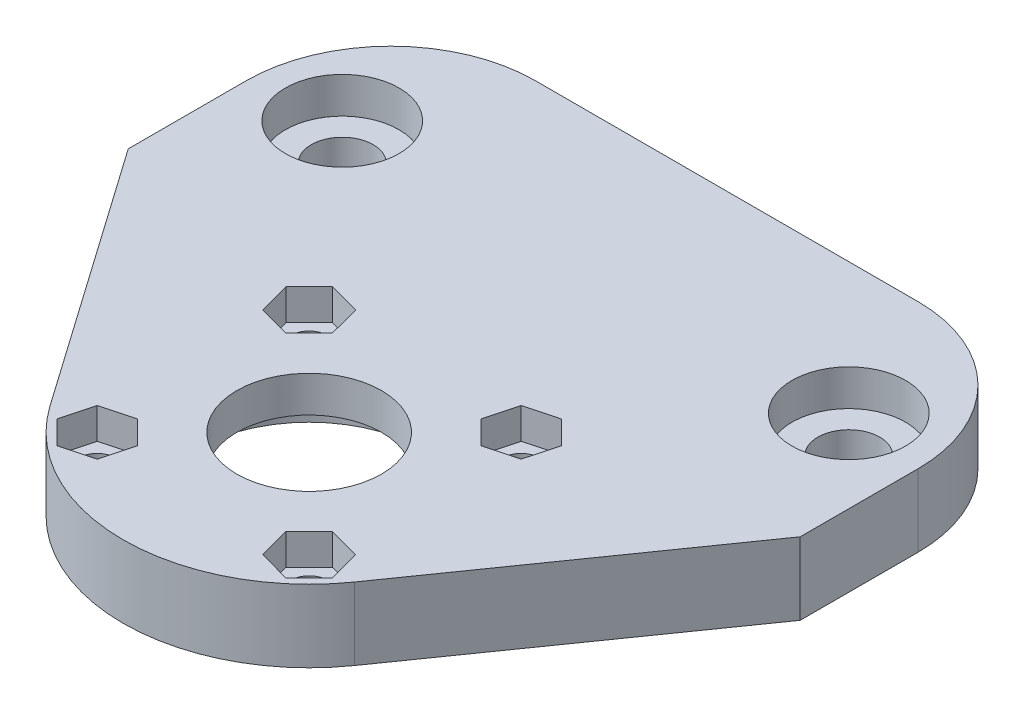
from build123d import *

# Parameters (mm, degrees)
SKETCH1_R           = 7
BOSS_EXTRUDE1_DEPTH = 7
SKETCH2_R           = 11.1
CUT_EXTRUDE1_DEPTH  = 3.5
SKETCH3_R           = 5.5
SKETCH3_R_2         = 3
CUT_EXTRUDE2_DEPTH  = 3.5
SKETCH3_2_R         = 3
CUT_EXTRUDE3_DEPTH  = 53.320263761
SKETCH4_R           = 1.75
CUT_EXTRUDE4_DEPTH  = 53.320263761
CUT_EXTRUDE5_DEPTH  = 3
FILLET1_R           = 14


with BuildPart() as part:
    # Sketch1 → Boss-Extrude1 (new body)
    with BuildSketch(Plane(origin=(0, 0, 0), x_dir=(1, 0, 0), z_dir=(0, 1, 0))):
        with BuildLine():
            Line((-32.5, 15), (-32.5, 40.4))
            Line((-32.5, 40.4), (32.5, 40.4))
            Line((32.5, 40.4), (32.5, 15))
            Line((32.5, 15), (14.738461184, -10.333332566))
            ThreePointArc((14.738461184, -10.333332566), (0, -18), (-14.738461184, -10.333332566))
            Line((-14.738461184, -10.333332566), (-32.5, 15))
        make_face()
        Circle(SKETCH1_R, mode=Mode.SUBTRACT)
    extrude(amount=BOSS_EXTRUDE1_DEPTH)

    # Sketch2 → Cut-Extrude1 (cut)
    with BuildSketch(Plane.XZ):
        Circle(SKETCH2_R)
    extrude(amount=-CUT_EXTRUDE1_DEPTH, mode=Mode.SUBTRACT)

    # Sketch3 → Cut-Extrude2 (cut)
    # profile 1 of 2: a face of its own
    with BuildSketch(Plane(origin=(0, 7, 0), x_dir=(1, 0, 0), z_dir=(0, 1, 0))):
        with Locations((24.5, 27.7)):
            Circle(SKETCH3_R)
        with Locations((24.5, 27.7)):
            Circle(SKETCH3_R_2, mode=Mode.SUBTRACT)
    # profile 2 of 2: a face of its own
    with BuildSketch(Plane(origin=(0, 7, 0), x_dir=(1, 0, 0), z_dir=(0, 1, 0))):
        with Locations((-24.5, 27.7)):
            Circle(SKETCH3_R)
        with Locations((-24.5, 27.7)):
            Circle(SKETCH3_R_2, mode=Mode.SUBTRACT)
    extrude(amount=-CUT_EXTRUDE2_DEPTH, mode=Mode.SUBTRACT)

    # Sketch3_2 → Cut-Extrude3 (cut, through all)
    with BuildSketch(Plane(origin=(0, 7, 0), x_dir=(1, 0, 0), z_dir=(0, 1, 0))):
        with Locations((24.5, 27.7)):
            Circle(SKETCH3_2_R)
        with Locations((-24.5, 27.7)):
            Circle(SKETCH3_2_R)
    extrude(amount=-CUT_EXTRUDE3_DEPTH, mode=Mode.SUBTRACT)

    # Sketch4 → Cut-Extrude4 (cut, through all)
    with BuildSketch(Plane.XZ):
        with Locations((10.253048327, 10.253048327)):
            Circle(SKETCH4_R)
        with Locations((10.253048327, -10.253048327)):
            Circle(SKETCH4_R)
        with Locations((-10.253048327, -10.253048327)):
            Circle(SKETCH4_R)
        with Locations((-10.253048327, 10.253048327)):
            Circle(SKETCH4_R)
    extrude(amount=-CUT_EXTRUDE4_DEPTH, mode=Mode.SUBTRACT)

    # Sketch5 → Cut-Extrude5 (cut)
    with BuildSketch(Plane(origin=(0, 7, 0), x_dir=(1, 0, 0), z_dir=(0, 1, 0))):
        Polygon((13.321494558, 11.070343295), (11.079473238, 13.319048197), (8.011027007, 12.501753229), (7.184602097, 9.435753359), (9.426623417, 7.187048458), (12.495069647, 8.004343425), align=None)
        Polygon((-11.070343295, 13.321494558), (-13.319048197, 11.079473238), (-12.501753229, 8.011027007), (-9.435753359, 7.184602097), (-7.187048458, 9.426623417), (-8.004343425, 12.495069647), align=None)
        Polygon((11.070343295, -13.321494558), (13.319048197, -11.079473238), (12.501753229, -8.011027007), (9.435753359, -7.184602097), (7.187048458, -9.426623417), (8.004343425, -12.495069647), align=None)
        Polygon((-13.321494558, -11.070343295), (-11.079473238, -13.319048197), (-8.011027007, -12.501753229), (-7.184602097, -9.435753359), (-9.426623417, -7.187048458), (-12.495069647, -8.004343425), align=None)
    extrude(amount=-CUT_EXTRUDE5_DEPTH, mode=Mode.SUBTRACT)

    # Fillet1
    fillet1_edges = [part.edges().sort_by_distance(p)[0] for p in [
        (-32.5, 3.5, -40.4),
        (32.5, 3.5, -40.4),
    ]]
    fillet(fillet1_edges, radius=FILLET1_R)


solid = part.part
